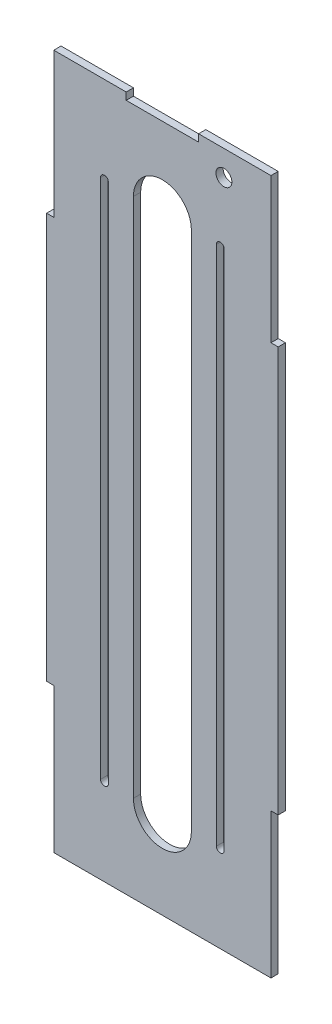
from build123d import *

# Parameters (mm, degrees)
SKETCH2_W                = 215.9
SKETCH2_H                = 609.6
BOSS_EXTRUDE1_DEPTH      = 6.35
CUT_EXTRUDE1_DEPTH       = 7.35
CUT_EXTRUDE2_DEPTH       = 1
CUT_EXTRUDE2_DEPTH_BACK  = 7.35
CUT_EXTRUDE3_DEPTH       = 1
CUT_EXTRUDE3_DEPTH_BACK  = 7.35
CUT_EXTRUDE6_DEPTH       = 1
CUT_EXTRUDE6_DEPTH_BACK  = 7.35
CUT_EXTRUDE7_DEPTH       = 1
CUT_EXTRUDE7_DEPTH_BACK  = 7.35
CUT_EXTRUDE11_DEPTH      = 1
CUT_EXTRUDE11_DEPTH_BACK = 7.35
CUT_EXTRUDE13_DEPTH      = 1
CUT_EXTRUDE13_DEPTH_BACK = 7.35
SKETCH13_W               = 63.5
SKETCH13_H               = 6.35
CUT_EXTRUDE14_DEPTH      = 1
CUT_EXTRUDE14_DEPTH_BACK = 7.35
CUT_EXTRUDE19_DEPTH      = 7.35
SKETCH26_R               = 6.985
CUT_EXTRUDE20_DEPTH      = 7.35


with BuildPart() as part:
    # Sketch2 → Boss-Extrude1 (new body)
    with BuildSketch(Plane.XY):
        with Locations((-911.126767395, 370.108550968)):
            Rectangle(SKETCH2_W, SKETCH2_H)
    extrude(amount=BOSS_EXTRUDE1_DEPTH)

    # Sketch3 → Cut-Extrude1 (cut, through all)
    with BuildSketch(Plane.XY.offset(6.35)):
        with BuildLine():
            Line((-936.526767395, 141.508550968), (-936.526767395, 598.708550968))
            ThreePointArc((-936.526767395, 598.708550968), (-911.126767395, 624.108550968), (-885.726767395, 598.708550968))
            Line((-885.726767395, 598.708550968), (-885.726767395, 141.508550968))
            ThreePointArc((-885.726767395, 141.508550968), (-911.126767395, 116.108550968), (-936.526767395, 141.508550968))
        make_face()
    extrude(amount=-CUT_EXTRUDE1_DEPTH, mode=Mode.SUBTRACT)

    # Sketch4 → Cut-Extrude2 (cut, two sides)
    with BuildSketch(Plane.XY.offset(6.35)) as cut_extrude2_sk:
        Polygon((-815.876767395, 1970.05819206), (-815.876767395, 674.908550968), (-815.876767395, 547.908550968), (-803.176767395, 547.908550968), (491.972873698, 547.908550968), (2398.607136056, 2301.304159748), (1090.757494964, 3723.45380084), align=None)
    extrude(amount=CUT_EXTRUDE2_DEPTH, mode=Mode.SUBTRACT)
    extrude(cut_extrude2_sk.sketch, amount=-CUT_EXTRUDE2_DEPTH_BACK, mode=Mode.SUBTRACT)

    # Sketch5 → Cut-Extrude3 (cut, two sides)
    with BuildSketch(Plane.XY.offset(6.35)) as cut_extrude3_sk:
        Polygon((-815.876767395, -1229.841090125), (-815.876767395, 65.308550968), (-815.876767395, 192.308550968), (-803.176767395, 192.308550968), (491.972873698, 192.308550968), (2398.607136056, -1561.087057812), (1090.757494964, -2983.236698905), align=None)
    extrude(amount=CUT_EXTRUDE3_DEPTH, mode=Mode.SUBTRACT)
    extrude(cut_extrude3_sk.sketch, amount=-CUT_EXTRUDE3_DEPTH_BACK, mode=Mode.SUBTRACT)

    # Sketch6 → Cut-Extrude6 (cut, two sides)
    with BuildSketch(Plane.XY.offset(6.35)) as cut_extrude6_sk:
        Polygon((-1006.376767395, 1970.05819206), (-1006.376767395, 674.908550968), (-1006.376767395, 547.908550968), (-1019.076767395, 547.908550968), (-2314.226408487, 547.908550968), (-4220.860670845, 2301.304159748), (-2913.011029753, 3723.45380084), align=None)
    extrude(amount=CUT_EXTRUDE6_DEPTH, mode=Mode.SUBTRACT)
    extrude(cut_extrude6_sk.sketch, amount=-CUT_EXTRUDE6_DEPTH_BACK, mode=Mode.SUBTRACT)

    # Sketch9 → Cut-Extrude7 (cut, two sides)
    with BuildSketch(Plane.XY.offset(6.35)) as cut_extrude7_sk:
        Polygon((-1006.376767395, -1229.841090125), (-1006.376767395, 65.308550968), (-1006.376767395, 192.308550968), (-1019.076767395, 192.308550968), (-2314.226408487, 192.308550968), (-4220.860670845, -1561.087057812), (-2913.011029753, -2983.236698905), align=None)
    extrude(amount=CUT_EXTRUDE7_DEPTH, mode=Mode.SUBTRACT)
    extrude(cut_extrude7_sk.sketch, amount=-CUT_EXTRUDE7_DEPTH_BACK, mode=Mode.SUBTRACT)

    # Sketch16 → Cut-Extrude11 (cut, two sides)
    with BuildSketch(Plane.XY.offset(6.35)) as cut_extrude11_sk:
        Polygon((-1012.726767395, -869.953702465), (-1012.726767395, 192.308550968), (-1012.726767395, 547.908550968), (-1012.726767395, 1610.170804401), (-3137.251274261, 1610.170804401), (-3137.251274261, -869.953702465), align=None)
    extrude(amount=CUT_EXTRUDE11_DEPTH, mode=Mode.SUBTRACT)
    extrude(cut_extrude11_sk.sketch, amount=-CUT_EXTRUDE11_DEPTH_BACK, mode=Mode.SUBTRACT)

    # Sketch17 → Cut-Extrude13 (cut, two sides)
    with BuildSketch(Plane.XY.offset(6.35)) as cut_extrude13_sk:
        Polygon((-809.526767395, -864.960277939), (-809.526767395, 192.308550968), (-809.526767395, 547.908550968), (-809.526767395, 1605.177379875), (1305.010890419, 1605.177379875), (1305.010890419, -864.960277939), align=None)
    extrude(amount=CUT_EXTRUDE13_DEPTH, mode=Mode.SUBTRACT)
    extrude(cut_extrude13_sk.sketch, amount=-CUT_EXTRUDE13_DEPTH_BACK, mode=Mode.SUBTRACT)

    # Sketch13 → Cut-Extrude14 (cut, two sides)
    with BuildSketch(Plane(origin=(0, 0, 0), x_dir=(-1, 0, 0), z_dir=(0, 0, -1))) as cut_extrude14_sk:
        with Locations((911.126767395, 671.733550968)):
            Rectangle(SKETCH13_W, SKETCH13_H)
    extrude(amount=CUT_EXTRUDE14_DEPTH, mode=Mode.SUBTRACT)
    extrude(cut_extrude14_sk.sketch, amount=-CUT_EXTRUDE14_DEPTH_BACK, mode=Mode.SUBTRACT)

    # Sketch25 → Cut-Extrude19 (cut, through all)
    with BuildSketch(Plane(origin=(0, 0, 0), x_dir=(-1, 0, 0), z_dir=(0, 0, -1))):
        with BuildLine():
            Line((958.497767395, 141.508550968), (958.497767395, 598.708550968))
            ThreePointArc((958.497767395, 598.708550968), (961.926767395, 602.137550968), (965.355767395, 598.708550968))
            Line((965.355767395, 598.708550968), (965.355767395, 141.508550968))
            ThreePointArc((965.355767395, 141.508550968), (961.926767395, 138.079550968), (958.497767395, 141.508550968))
        make_face()
    cut_extrude19 = extrude(amount=-CUT_EXTRUDE19_DEPTH, mode=Mode.SUBTRACT)

    # Mirror1: Cut-Extrude19 across plane
    add(cut_extrude19.mirror(Plane(origin=(-911.126767395, 0, 0), x_dir=(0, 0, 1), z_dir=(1, 0, 0))), mode=Mode.SUBTRACT)

    # Sketch26 → Cut-Extrude20 (cut, through all)
    with BuildSketch(Plane.XY.offset(6.35)):
        with Locations((-857.158491521, 652.784891731)):
            Circle(SKETCH26_R)
    extrude(amount=-CUT_EXTRUDE20_DEPTH, mode=Mode.SUBTRACT)


solid = part.part
